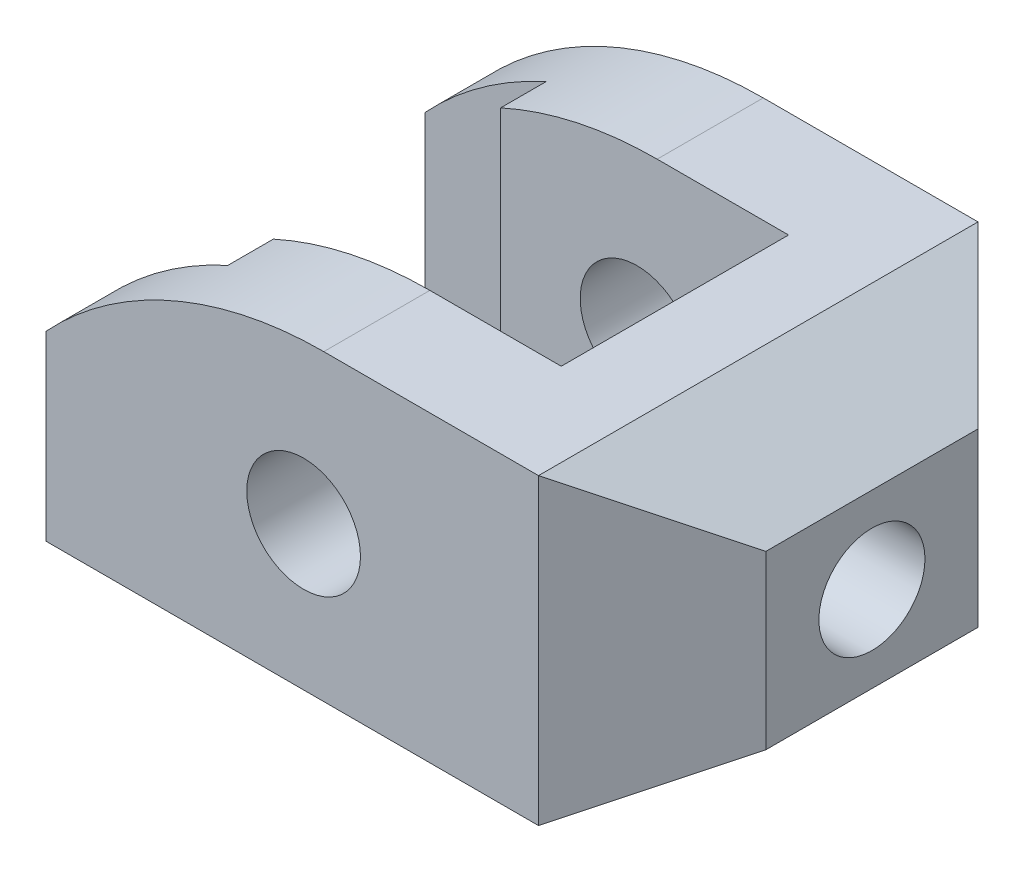
from build123d import *

# Parameters (mm, degrees)
SKETCH1_R                = 7.5
BOSS_EXTRUDE1_DEPTH      = 58
SKETCH5_R                = 7
CUT_EXTRUDE1_DEPTH       = 81
CUT_EXTRUDE3_DEPTH       = 22.0000001
CUT_EXTRUDE3_DEPTH_BACK  = 20
SKETCH7_W                = 16
SKETCH7_H                = 6
CUT_EXTRUDE5_DEPTH       = 22
CUT_EXTRUDE5_DEPTH_BACK  = 20
CUT_EXTRUDE14_DEPTH      = 24
CUT_EXTRUDE14_DEPTH_BACK = 24


with BuildPart() as part:
    # Sketch1 → Boss-Extrude1 (new body)
    with BuildSketch(Plane.XY):
        with BuildLine():
            Line((-34, -19), (31, -19))
            Line((31, -19), (46, -10.339745962))
            Line((46, -10.339745962), (46, 12.339745962))
            Line((46, 12.339745962), (31, 21))
            Line((31, 21), (2.66060556, 21))
            ThreePointArc((2.66060556, 21), (-17.33939444, 16.82575695), (-34, 5))
            Line((-34, 5), (-34, -19))
        make_face()
        Circle(SKETCH1_R, mode=Mode.SUBTRACT)
    extrude(amount=BOSS_EXTRUDE1_DEPTH)

    # Sketch5 → Cut-Extrude1 (cut, through all)
    with BuildSketch(Plane(origin=(46, 0, 0), x_dir=(0, 0, -1), z_dir=(1, 0, 0))):
        with Locations((-29, 1)):
            Circle(SKETCH5_R)
    extrude(amount=-CUT_EXTRUDE1_DEPTH, mode=Mode.SUBTRACT)

    # Sketch6 → Cut-Extrude3 (cut, two sides)
    with BuildSketch(Plane(origin=(0, 0, 0), x_dir=(1, 0, 0), z_dir=(0, 1, 0))) as cut_extrude3_sk:
        Polygon((-226.60339564, -14), (-34, -14), (20, -14), (20, -44), (-34, -44), (-226.60339564, -44), (-611.81018692, -44), (-611.81018692, -14), align=None)
    extrude(amount=CUT_EXTRUDE3_DEPTH, mode=Mode.SUBTRACT)
    extrude(cut_extrude3_sk.sketch, amount=-CUT_EXTRUDE3_DEPTH_BACK, mode=Mode.SUBTRACT)

    # Sketch7 → Cut-Extrude5 (cut, two sides)
    with BuildSketch(Plane(origin=(0, 0, 0), x_dir=(1, 0, 0), z_dir=(0, 1, 0))) as cut_extrude5_sk:
        with Locations((-26, -11)):
            Rectangle(SKETCH7_W, SKETCH7_H)
        with Locations((-26, -47)):
            Rectangle(SKETCH7_W, SKETCH7_H)
    extrude(amount=CUT_EXTRUDE5_DEPTH, mode=Mode.SUBTRACT)
    extrude(cut_extrude5_sk.sketch, amount=-CUT_EXTRUDE5_DEPTH_BACK, mode=Mode.SUBTRACT)

    # Sketch14 → Cut-Extrude14 (cut, two sides)
    with BuildSketch(Plane(origin=(0, 0, 0), x_dir=(1, 0, 0), z_dir=(0, 1, 0))) as cut_extrude14_sk:
        Polygon((31, 0), (46, 0), (46, -15), align=None)
        Polygon((31, -58), (46, -58), (46, -43), align=None)
    extrude(amount=CUT_EXTRUDE14_DEPTH, mode=Mode.SUBTRACT)
    extrude(cut_extrude14_sk.sketch, amount=-CUT_EXTRUDE14_DEPTH_BACK, mode=Mode.SUBTRACT)


solid = part.part
